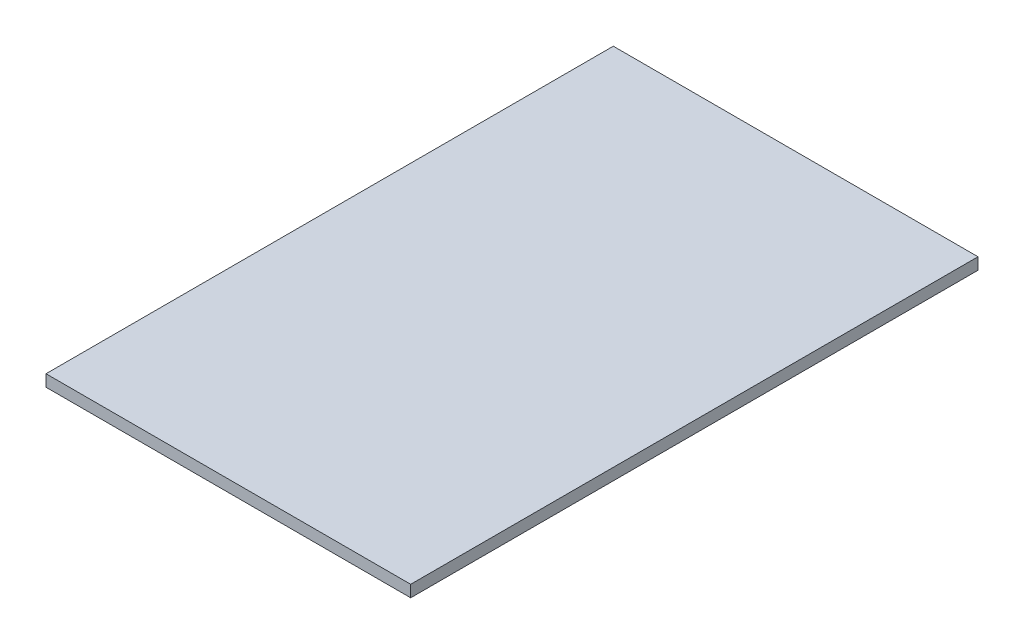
from build123d import *

# Parameters (mm, degrees)
SKETCH3_W           = 49.5
SKETCH3_H           = 77
BOSS_EXTRUDE1_DEPTH = 1.59


with BuildPart() as part:
    # Sketch3 → Boss-Extrude1 (new body)
    with BuildSketch(Plane(origin=(0, 0, 0), x_dir=(1, 0, 0), z_dir=(0, 1, 0))):
        with Locations((24.75, 38.5)):
            Rectangle(SKETCH3_W, SKETCH3_H)
    extrude(amount=BOSS_EXTRUDE1_DEPTH)


solid = part.part
